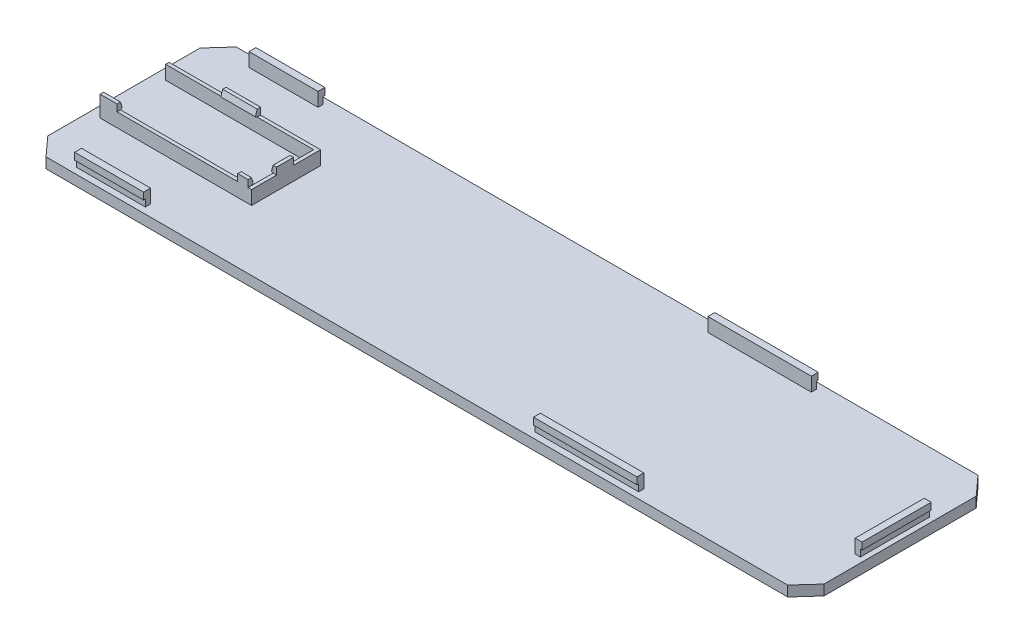
from build123d import *

# Parameters (mm, degrees)
SALIENTE_EXTRUIR1_DEPTH  = 3
CROQUIS2_W               = 2
CROQUIS2_H               = 20
CROQUIS2_W_2             = 20
CROQUIS2_H_2             = 2
CROQUIS2_W_3             = 30
SALIENTE_EXTRUIR2_DEPTH  = 4
CROQUIS3_W               = 10
CROQUIS3_H               = 1
CROQUIS3_W_2             = 1
CROQUIS3_H_2             = 4.894277734
CROQUIS3_W_3             = 3
CROQUIS3_W_4             = 5
SALIENTE_EXTRUIR3_DEPTH  = 2
SALIENTE_EXTRUIR4_DEPTH  = 10
SALIENTE_EXTRUIR8_DEPTH  = 5
SALIENTE_EXTRUIR9_DEPTH  = 5
SALIENTE_EXTRUIR10_DEPTH = 3
CROQUIS8_W               = 20
CROQUIS8_H               = 6
CORTAR_EXTRUIR1_DEPTH    = 0.1
CROQUIS10_W              = 0.5
CROQUIS10_H              = 2
CORTAR_EXTRUIR2_DEPTH    = 199.1
CROQUIS11_W              = 0.5
CROQUIS11_H              = 2
CORTAR_EXTRUIR3_DEPTH    = 199.1
CROQUIS12_W              = 0.5
CROQUIS12_H              = 2
CORTAR_EXTRUIR4_DEPTH    = 199.1


with BuildPart() as part:
    # Croquis1 → Saliente-Extruir1 (new body)
    with BuildSketch(Plane(origin=(0, 0, 0), x_dir=(1, 0, 0), z_dir=(0, 1, 0))):
        Polygon((-84.217677887, 21.218806135), (130.782322113, 21.218806135), (135.782322113, 15.698806135), (135.782322113, -28.430089815), (130.782322113, -33.950089815), (-84.217677887, -33.950089815), (-89.217677887, -28.430089815), (-89.217677887, 15.698806135), align=None)
        Polygon((-86.217677887, 14.328120868), (-86.217677887, -27.059404549), (-82.974424711, -30.639956055), (129.539068937, -30.639956055), (132.782322113, -27.059404549), (132.782322113, 14.328120868), (129.539068937, 17.908672375), (-82.974424711, 17.908672375), align=None, mode=Mode.SUBTRACT)
        Polygon((-86.217677887, 14.328120868), (-82.974424711, 17.908672375), (129.539068937, 17.908672375), (132.782322113, 14.328120868), (132.782322113, -27.059404549), (129.539068937, -30.639956055), (-82.974424711, -30.639956055), (-86.217677887, -27.059404549), align=None)
    extrude(amount=SALIENTE_EXTRUIR1_DEPTH)

    # Croquis2 → Saliente-Extruir2 (add)
    with BuildSketch(Plane(origin=(0, 3, 0), x_dir=(1, 0, 0), z_dir=(0, 1, 0))):
        Polygon((-86.217677887, 3.63435816), (-86.217677887, 2.63435816), (-43.217677887, 2.63435816), (-43.217677887, -15.36564184), (-86.217677887, -15.36564184), (-86.217677887, -16.36564184), (-42.217677887, -16.36564184), (-42.217677887, 3.63435816), align=None)
        with Locations((133.782322113, -6.36564184)):
            Rectangle(CROQUIS2_W, CROQUIS2_H)
        with Locations((-67.217677887, 18.908672375)):
            Rectangle(CROQUIS2_W_2, CROQUIS2_H_2)
        with Locations((-67.217677887, -31.639956055)):
            Rectangle(CROQUIS2_W_2, CROQUIS2_H_2)
        with Locations((70.782322113, 18.908672375)):
            Rectangle(CROQUIS2_W_3, CROQUIS2_H_2)
        with Locations((70.782322113, -31.639956055)):
            Rectangle(CROQUIS2_W_3, CROQUIS2_H_2)
    extrude(amount=SALIENTE_EXTRUIR2_DEPTH)

    # Croquis3 → Saliente-Extruir3 (add)
    with BuildSketch(Plane(origin=(0, 7, 0), x_dir=(1, 0, 0), z_dir=(0, 1, 0))):
        with Locations((-64.600820338, 3.13435816)):
            Rectangle(CROQUIS3_W, CROQUIS3_H)
        with Locations((-42.717677887, -6.653976659)):
            Rectangle(CROQUIS3_W_2, CROQUIS3_H_2)
        with Locations((-44.717677887, -15.86564184)):
            Rectangle(CROQUIS3_W_3, CROQUIS3_H)
        with Locations((-83.717677887, -15.86564184)):
            Rectangle(CROQUIS3_W_4, CROQUIS3_H)
    extrude(amount=SALIENTE_EXTRUIR3_DEPTH)

    # Croquis4 → Saliente-Extruir4 (add)
    with BuildSketch(Plane.ZY.offset(69.600820338)):
        Polygon((-2.63435816, 9), (-2.13435816, 7.3), (-2.63435816, 7), align=None)
    extrude(amount=-SALIENTE_EXTRUIR4_DEPTH)

    # Croquis6 → Saliente-Extruir9 (add)
    with BuildSketch(Plane.ZY.offset(86.217677887)):
        Polygon((15.36564184, 9), (14.86564184, 7.3), (15.36564184, 7), align=None)
    extrude(amount=-SALIENTE_EXTRUIR9_DEPTH)

    # Croquis7 → Saliente-Extruir10 (add)
    with BuildSketch(Plane.ZY.offset(46.217677887)):
        Polygon((15.36564184, 9), (14.86564184, 7.3), (15.36564184, 7), align=None)
    extrude(amount=-SALIENTE_EXTRUIR10_DEPTH)

    # Croquis8 → Cortar-Extruir1 (cut)
    with BuildSketch(Plane.ZY.offset(86.217677887)):
        with Locations((6.36564184, 6)):
            Rectangle(CROQUIS8_W, CROQUIS8_H)
    extrude(amount=-CORTAR_EXTRUIR1_DEPTH, mode=Mode.SUBTRACT)

    # Croquis10 → Cortar-Extruir2 (cut)
    with BuildSketch(Plane.ZY.offset(77.217677887)):
        with Locations((-19.658672375, 4)):
            Rectangle(CROQUIS10_W, CROQUIS10_H)
    extrude(amount=-CORTAR_EXTRUIR2_DEPTH, mode=Mode.SUBTRACT)

    # Croquis11 → Cortar-Extruir3 (cut)
    with BuildSketch(Plane.ZY.offset(77.217677887)):
        with Locations((32.389956055, 4)):
            Rectangle(CROQUIS11_W, CROQUIS11_H)
    extrude(amount=-CORTAR_EXTRUIR3_DEPTH, mode=Mode.SUBTRACT)

    # Croquis12 → Cortar-Extruir4 (cut)
    with BuildSketch(Plane.XY.offset(16.36564184)):
        with Locations((134.532322113, 4)):
            Rectangle(CROQUIS12_W, CROQUIS12_H)
    extrude(amount=-CORTAR_EXTRUIR4_DEPTH, mode=Mode.SUBTRACT)


with BuildPart() as body_2:
    # Croquis5 → Saliente-Extruir8 (new body)
    with BuildSketch(Plane.XY.offset(9.101115526)):
        Polygon((-43.217677887, 9), (-43.717677887, 7.3), (-43.217677887, 7), align=None)
    extrude(amount=-SALIENTE_EXTRUIR8_DEPTH)


solid = Compound([part.part, body_2.part])
